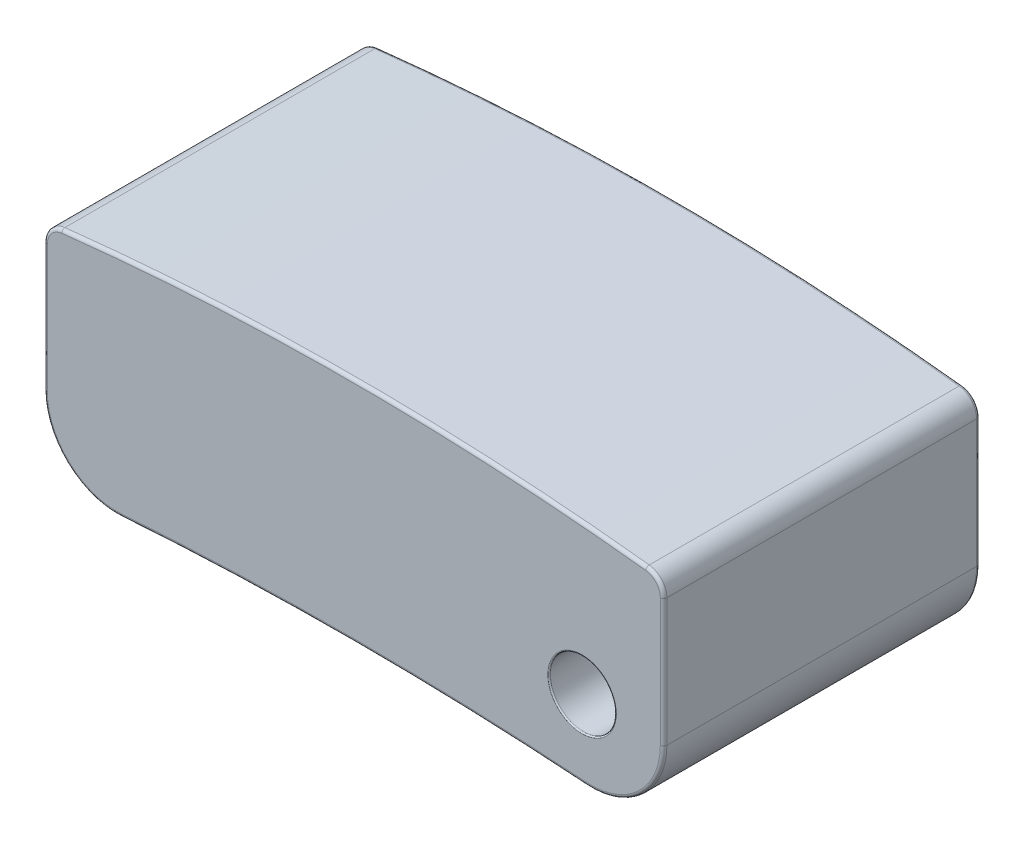
from build123d import *

# Parameters (mm, degrees)
SKETCH1_W               = 9.4
SKETCH1_H               = 3.7
BOSS_EXTRUDE1_DEPTH     = 2.4
CUT_EXTRUDE1_DEPTH      = 4.8
FILLET1_R               = 1.1
FILLET2_R               = 0.3
FILLET3_R               = 0.05
SKETCH3_R               = 0.5
CUT_EXTRUDE2_DEPTH      = 4.8
FILLET4_R               = 0.02
SKETCH4_W               = 1.881576533
SKETCH4_H               = 1.177564348
BOSS_EXTRUDE2_DEPTH     = 1
SKETCH5_R               = 0.5
CUT_EXTRUDE3_DEPTH      = 10
SKETCH6_R               = 0.867809029
BOSS_EXTRUDE3_DEPTH     = 1
CUT_EXTRUDE4_REACH      = 17.585
CUT_EXTRUDE4_END_RADIUS = 50.4
CUT_EXTRUDE4_START      = -10
SKETCH7_R               = 0.4
FILLET5_R               = 0.05


with BuildPart() as part:
    # Sketch1 → Boss-Extrude1 (new, symmetric)
    with BuildSketch(Plane.XY):
        Rectangle(SKETCH1_W, SKETCH1_H)
    extrude(amount=BOSS_EXTRUDE1_DEPTH, both=True)

    # Sketch2 → Cut-Extrude1 (cut)
    with BuildSketch(Plane.XY.offset(2.4)):
        with BuildLine():
            Line((-4.7, 1.55), (-7.120690005, 4.011417256))
            Line((-7.120690005, 4.011417256), (5.535860742, 3.886722174))
            Line((5.535860742, 3.886722174), (4.7, 1.55))
            ThreePointArc((4.7, 1.55), (0, 1.827084699), (-4.7, 1.55))
        make_face()
        with BuildLine():
            Line((4.7, -1.85), (0.350623614, -3.782025322))
            Line((0.350623614, -3.782025322), (-4.7, -1.85))
            ThreePointArc((-4.7, -1.85), (0, -1.628609864), (4.7, -1.85))
        make_face()
    extrude(amount=-CUT_EXTRUDE1_DEPTH, mode=Mode.SUBTRACT)

    # Fillet1
    fillet1_edges = [part.edges().sort_by_distance(p)[0] for p in [
        (4.7, -1.85, 0),
        (-4.7, -1.85, 0),
    ]]
    fillet(fillet1_edges, radius=FILLET1_R)

    # Fillet2
    fillet2_edges = [part.edges().sort_by_distance(p)[0] for p in [
        (4.7, 1.55, 0),
        (-4.7, 1.55, 0),
    ]]
    fillet(fillet2_edges, radius=FILLET2_R)

    # Fillet3
    fillet3_edges = [part.edges().sort_by_distance(p)[0] for p in [
        (4.7, 0.3134624, -2.4),
        (4.7, 0.3134624, 2.4),
        (0, -1.628609864, -2.4),
        (-4.349918456, -1.460327621, -2.4),
        (4.349918456, -1.460327621, -2.4),
        (0, -1.628609864, 2.4),
        (-4.349918456, -1.460327621, 2.4),
        (4.349918456, -1.460327621, 2.4),
        (0, 1.827084699, 2.4),
        (-4.7, 0.3134624, 2.4),
        (-4.623578634, 1.482534062, 2.4),
        (4.623578634, 1.482534062, 2.4),
        (0, 1.827084699, -2.4),
        (-4.7, 0.3134624, -2.4),
        (-4.623578634, 1.482534062, -2.4),
        (4.623578634, 1.482534062, -2.4),
    ]]
    fillet(fillet3_edges, radius=FILLET3_R)

    # Sketch3 → Cut-Extrude2 (cut)
    with BuildSketch(Plane.XY.offset(2.4)):
        with Locations((3.462563269, -0.578744651)):
            Circle(SKETCH3_R)
    cut_extrude2 = extrude(amount=-CUT_EXTRUDE2_DEPTH, mode=Mode.SUBTRACT)

    # Fillet4
    fillet4_edges = [part.edges().sort_by_distance(p)[0] for p in [
        (2.962563269, -0.578744651, -2.4),
        (2.962563269, -0.578744651, 2.4),
    ]]
    fillet(fillet4_edges, radius=FILLET4_R)

    # Mirror1: Cut-Extrude2 across plane
    add(cut_extrude2.mirror(Plane(origin=(0, 0, 0), x_dir=(0, 0, 1), z_dir=(1, 0, 0))), mode=Mode.SUBTRACT)

    # Sketch4 → Boss-Extrude2 (add)
    with BuildSketch(Plane.XY.offset(2.4)):
        with Locations((-3.353123346, -0.588782174)):
            Rectangle(SKETCH4_W, SKETCH4_H)
    extrude(amount=-BOSS_EXTRUDE2_DEPTH)

    # Sketch5 → Cut-Extrude3 (cut)
    with BuildSketch(Plane(origin=(0, 0, 1.4), x_dir=(-1, 0, 0), z_dir=(0, 0, -1))):
        with Locations(Location((3.462563269, -0.578744651, 0), (0, 0, 180))):
            Circle(SKETCH5_R)
    extrude(amount=-CUT_EXTRUDE3_DEPTH, mode=Mode.SUBTRACT)

    # Sketch6 → Boss-Extrude3 (add)
    with BuildSketch(Plane.XY.offset(2.4)):
        with Locations((-3.432599982, -0.500417585)):
            Circle(SKETCH6_R)
    extrude(amount=-BOSS_EXTRUDE3_DEPTH)

    # Cut-Extrude4: up to this cylinder (the profile starts inside it)
    cut_extrude4_end = Plane(origin=(0, -51.628609864, -0.9), z_dir=(0, 0, 1)) * Cylinder(CUT_EXTRUDE4_END_RADIUS, 136.97, mode=Mode.PRIVATE)
    # Sketch7 → Cut-Extrude4 (cut, up to the surface)
    with BuildSketch(Plane(origin=(0, 0, 0), x_dir=(1, 0, 0), z_dir=(0, 1, 0)).offset(CUT_EXTRUDE4_START), mode=Mode.PRIVATE) as cut_extrude4_sk1:
        with Locations(Location((-0.7, 0.9, 0), (0, 0, 90))):
            Circle(SKETCH7_R)
    cut_extrude4_tool1 = extrude(cut_extrude4_sk1.sketch, amount=CUT_EXTRUDE4_REACH, mode=Mode.PRIVATE) & cut_extrude4_end
    add(cut_extrude4_tool1.solids().sort_by_distance((-0.7, -10, -0.9))[0], mode=Mode.SUBTRACT)

    # Fillet5
    fillet5_edges = [part.edges().sort_by_distance(p)[0] for p in [
        (-0.700029875, -1.633510522, -0.500000001),
    ]]
    fillet(fillet5_edges, radius=FILLET5_R)


solid = part.part
